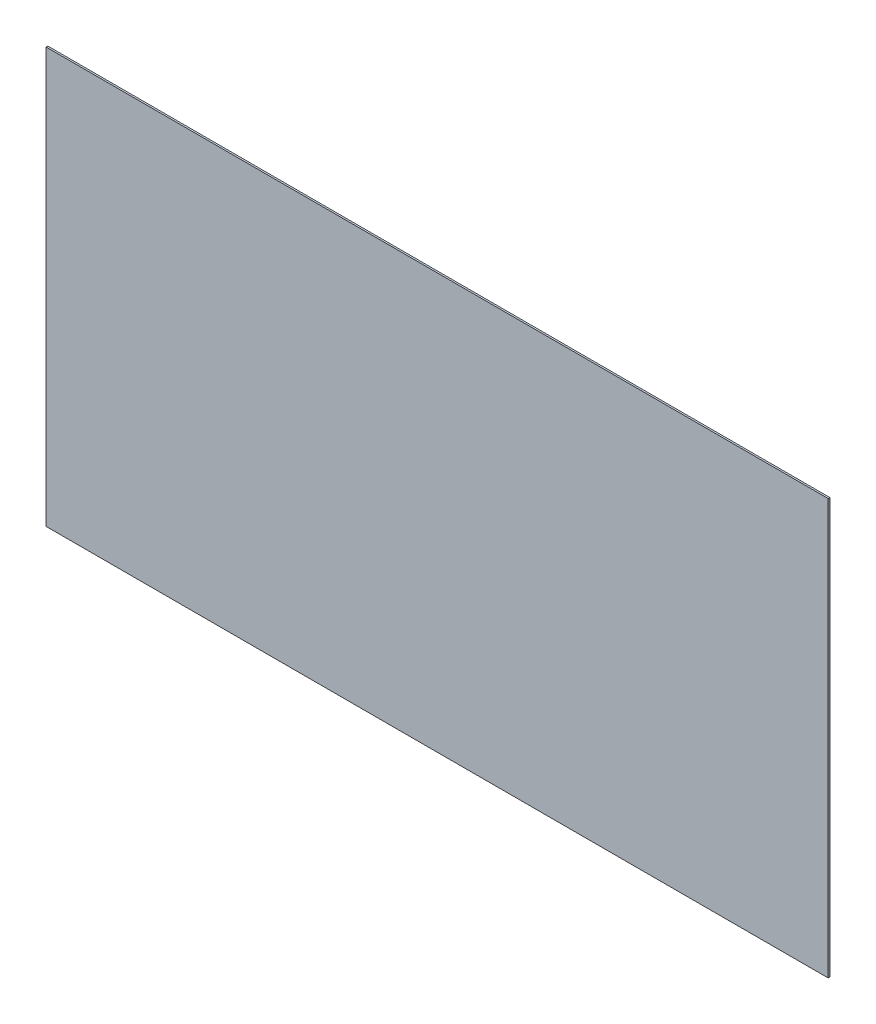
from build123d import *

# Parameters (mm, degrees)
SKETCH1_W           = 717.804
SKETCH1_H           = 381
BOSS_EXTRUDE1_DEPTH = 1.5875


with BuildPart() as part:
    # Sketch1 → Boss-Extrude1 (new body)
    with BuildSketch(Plane.XY):
        with Locations((358.902, 190.5)):
            Rectangle(SKETCH1_W, SKETCH1_H)
    extrude(amount=BOSS_EXTRUDE1_DEPTH)


solid = part.part
